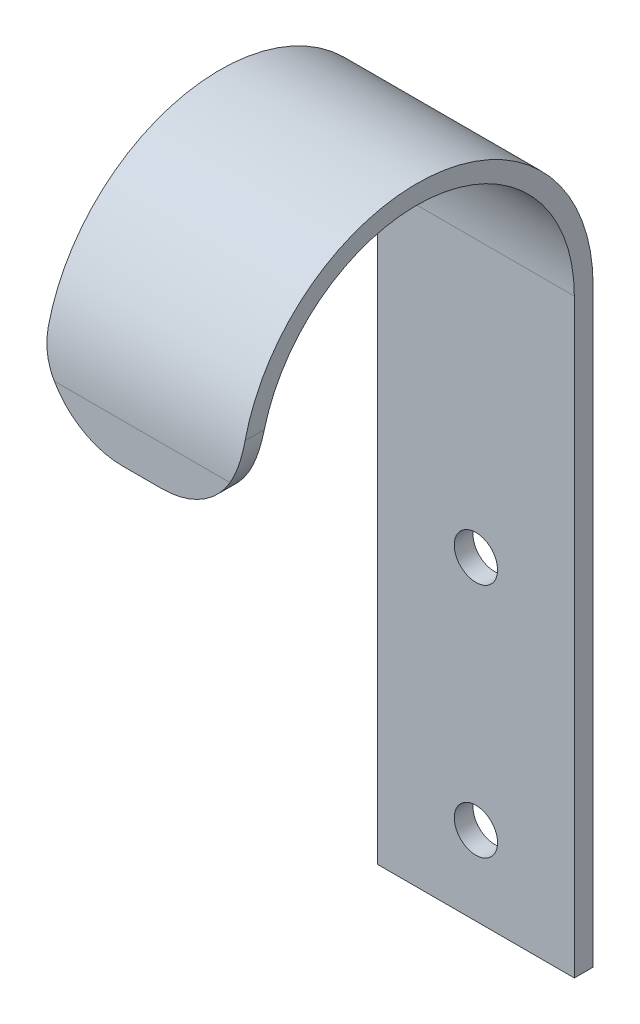
from build123d import *

# Parameters (mm, degrees)
BOSS_EXTRUDE1_DEPTH = 25
FILLET1_R           = 10
SKETCH2_R           = 2.75
CUT_EXTRUDE1_DEPTH  = 25


with BuildPart() as part:
    # Sketch1 → Boss-Extrude1 (new body)
    with BuildSketch(Plane(origin=(0, 0, 0), x_dir=(0, 0, -1), z_dir=(1, 0, 0))):
        with BuildLine():
            Line((0, 0), (0, 75))
            ThreePointArc((0, 75), (-20, 95), (-40, 75))
            Line((-40, 75), (-40, 70))
            Line((-40, 70), (-42.38, 70))
            Line((-42.38, 70), (-42.38, 75))
            ThreePointArc((-42.38, 75), (-20, 97.38), (2.38, 75))
            Line((2.38, 75), (2.38, 0))
            Line((2.38, 0), (0, 0))
        make_face()
    extrude(amount=BOSS_EXTRUDE1_DEPTH)

    # Fillet1
    fillet1_edges = [part.edges().sort_by_distance(p)[0] for p in [
        (0, 70, 41.19),
        (25, 70, 41.19),
    ]]
    fillet(fillet1_edges, radius=FILLET1_R)

    # Sketch2 → Cut-Extrude1 (cut)
    with BuildSketch(Plane.XY):
        with Locations((12.5, 10)):
            Circle(SKETCH2_R)
        with Locations((12.5, 40)):
            Circle(SKETCH2_R)
    extrude(amount=-CUT_EXTRUDE1_DEPTH, mode=Mode.SUBTRACT)


solid = part.part
